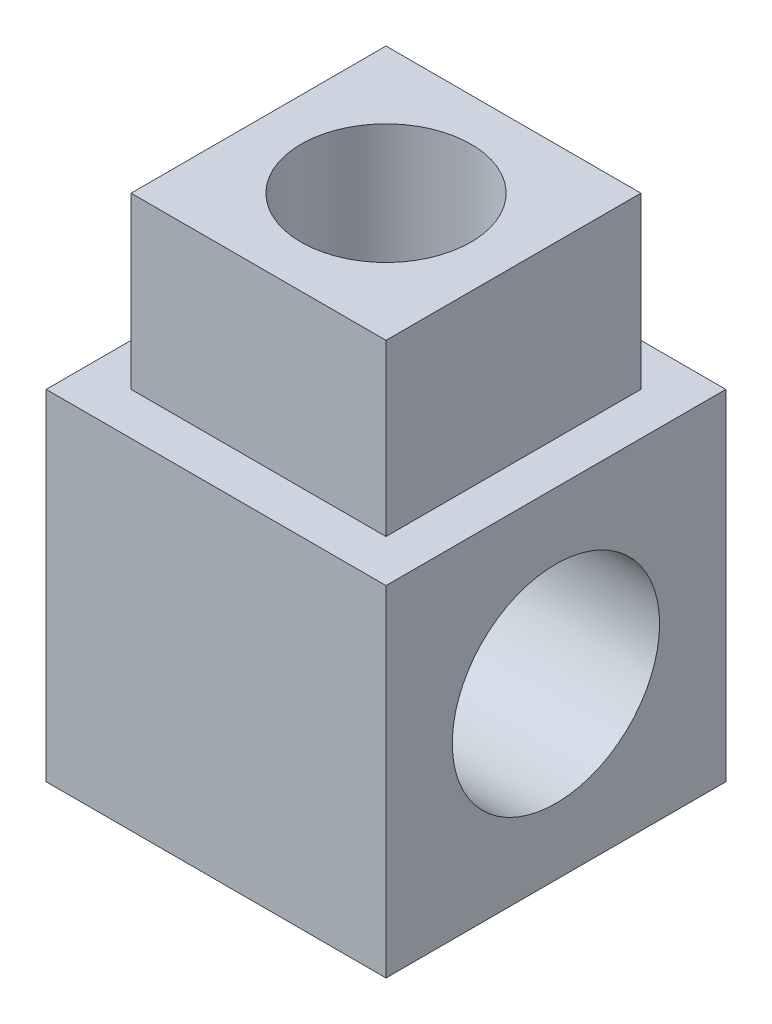
from build123d import *

# Parameters (mm, degrees)
SKETCH1_W           = 20
SKETCH1_H           = 20
SKETCH1_R           = 6.1
BOSS_EXTRUDE1_DEPTH = 10
SKETCH2_W           = 15
SKETCH2_H           = 15
BOSS_EXTRUDE2_DEPTH = 10
SKETCH3_R           = 5
CUT_EXTRUDE1_DEPTH  = 10


with BuildPart() as part:
    # Sketch1 → Boss-Extrude1 (new body, symmetric)
    with BuildSketch(Plane(origin=(0, 0, 0), x_dir=(0, 0, -1), z_dir=(1, 0, 0))):
        Rectangle(SKETCH1_W, SKETCH1_H)
        Circle(SKETCH1_R, mode=Mode.SUBTRACT)
    extrude(amount=BOSS_EXTRUDE1_DEPTH, both=True)

    # Sketch2 → Boss-Extrude2 (add)
    with BuildSketch(Plane(origin=(0, 10, 0), x_dir=(1, 0, 0), z_dir=(0, 1, 0))):
        Rectangle(SKETCH2_W, SKETCH2_H)
    extrude(amount=BOSS_EXTRUDE2_DEPTH)

    # Sketch3 → Cut-Extrude1 (cut)
    with BuildSketch(Plane(origin=(0, 20, 0), x_dir=(1, 0, 0), z_dir=(0, 1, 0))):
        Circle(SKETCH3_R)
    extrude(amount=-CUT_EXTRUDE1_DEPTH, mode=Mode.SUBTRACT)


solid = part.part
